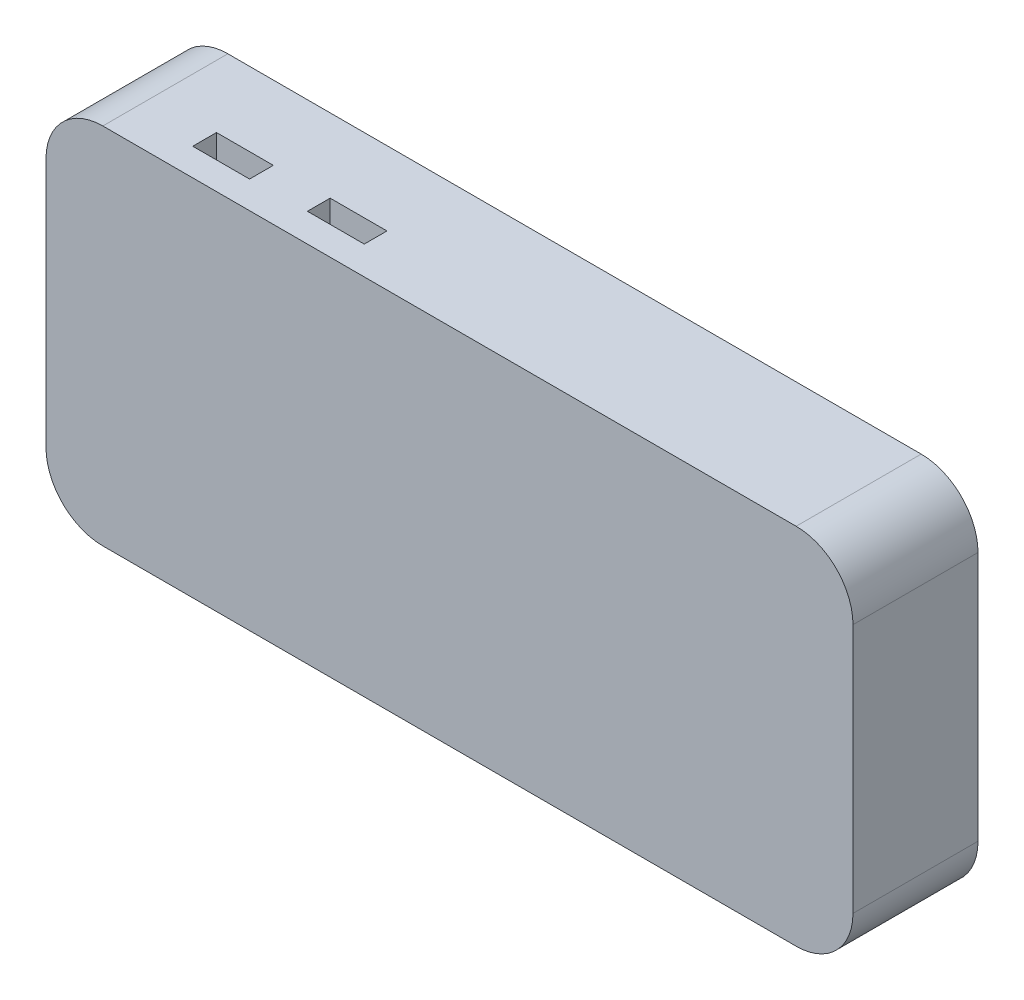
from build123d import *

# Parameters (mm, degrees)
BOSS_EXTRUDE1_DEPTH = 22
SKETCH2_W           = 5
SKETCH2_H           = 13
CUT_EXTRUDE1_DEPTH  = 10
SKETCH3_W           = 10
SKETCH3_H           = 4
SKETCH3_H_2         = 4.178443519
CUT_EXTRUDE2_DEPTH  = 5


with BuildPart() as part:
    # Sketch1 → Boss-Extrude1 (new body)
    with BuildSketch(Plane.XY):
        with BuildLine():
            Line((-61, 32), (61, 32))
            ThreePointArc((61, 32), (68.071067812, 29.071067812), (71, 22))
            Line((71, 22), (71, -22))
            ThreePointArc((71, -22), (68.071067812, -29.071067812), (61, -32))
            Line((61, -32), (-61, -32))
            ThreePointArc((-61, -32), (-68.071067812, -29.071067812), (-71, -22))
            Line((-71, -22), (-71, 22))
            ThreePointArc((-71, 22), (-68.071067812, 29.071067812), (-61, 32))
        make_face()
    extrude(amount=BOSS_EXTRUDE1_DEPTH)

    # Sketch2 → Cut-Extrude1 (cut)
    with BuildSketch(Plane.ZY.offset(71)):
        with Locations((15.5, 19.5)):
            Rectangle(SKETCH2_W, SKETCH2_H)
        with Locations((6.5, 19.5)):
            Rectangle(SKETCH2_W, SKETCH2_H)
    extrude(amount=-CUT_EXTRUDE1_DEPTH, mode=Mode.SUBTRACT)

    # Sketch3 → Cut-Extrude2 (cut)
    with BuildSketch(Plane(origin=(0, 32, 0), x_dir=(1, 0, 0), z_dir=(0, 1, 0))):
        with Locations((-25, -15)):
            Rectangle(SKETCH3_W, SKETCH3_H)
        with Locations((-45, -15.08922176)):
            Rectangle(SKETCH3_W, SKETCH3_H_2)
    extrude(amount=-CUT_EXTRUDE2_DEPTH, mode=Mode.SUBTRACT)


solid = part.part
